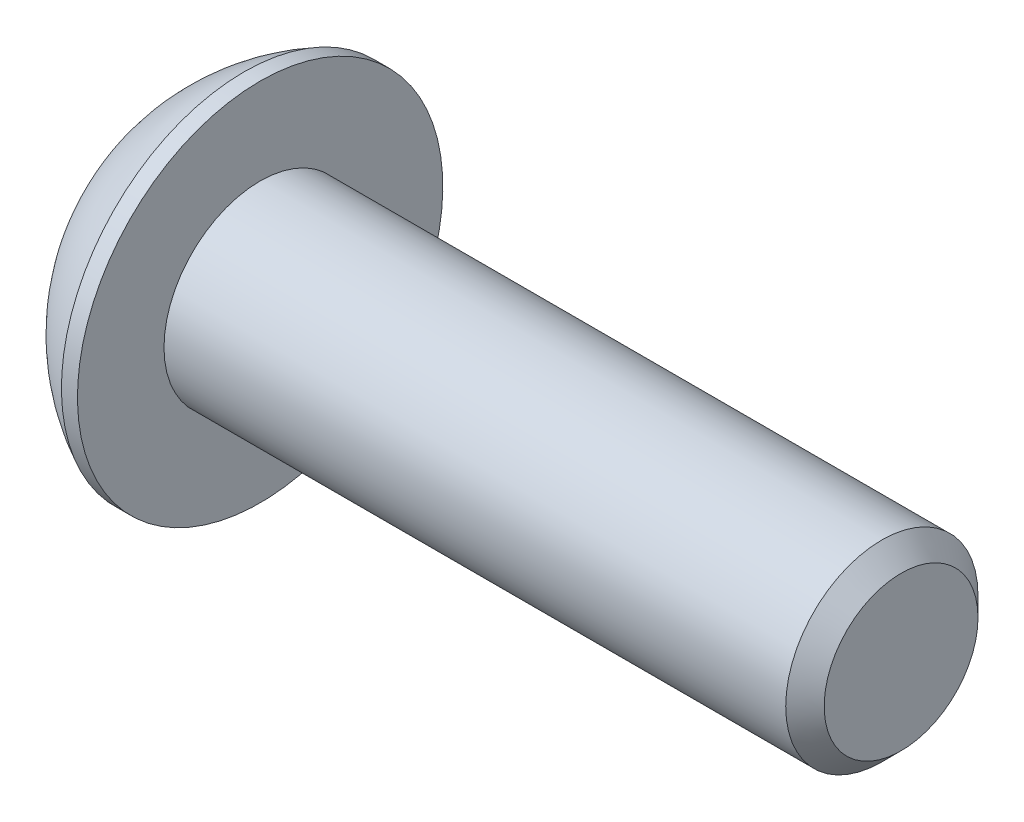
from build123d import *

# Parameters (mm, degrees)
SKETCH2_R           = 1.5
BOSS_EXTRUDE1_DEPTH = 10
CHAMFER1_SIZE       = 0.3
CUT_EXTRUDE1_DEPTH  = 1.2
SKETCH8_R           = 1.204700538
CUT_EXTRUDE2_DEPTH  = 1
CUT_EXTRUDE2_TAPER  = 45


with BuildPart() as part:
    # Sketch2 → Boss-Extrude1 (new body)
    with BuildSketch(Plane(origin=(0, 0, 0), x_dir=(0, 0, -1), z_dir=(1, 0, 0))):
        Circle(SKETCH2_R)
    extrude(amount=-BOSS_EXTRUDE1_DEPTH)

    # Chamfer1
    chamfer1_edges = [part.edges().sort_by_distance(p)[0] for p in [
        (0, 0, 1.5),
    ]]
    chamfer(chamfer1_edges, length=CHAMFER1_SIZE)

    # Sketch6 → Revolve1 (revolve)
    with BuildSketch(Plane.XY):
        with BuildLine():
            Line((-11.65, 0), (-11.65, 1.5))
            ThreePointArc((-11.65, 1.5), (-11.055944823, 2.284868705), (-10.25, 2.85))
            Line((-10.25, 2.85), (-10, 2.85))
            Line((-10, 2.85), (-10, 0))
            Line((-10, 0), (-11.65, 0))
        make_face()
    revolve(axis=Axis((-10, 0, 0), (-1, 0, 0)))

    # Sketch7 → Cut-Extrude1 (cut)
    with BuildSketch(Plane.ZY.offset(11.65)):
        Polygon((0, 1.154700538), (-1, 0.577350269), (-1, -0.577350269), (0, -1.154700538), (1, -0.577350269), (1, 0.577350269), align=None)
    extrude(amount=-CUT_EXTRUDE1_DEPTH, mode=Mode.SUBTRACT)

    # Sketch8 → Cut-Extrude2 (cut)
    with BuildSketch(Plane.ZY.offset(11.65)):
        Circle(SKETCH8_R)
    extrude(amount=-CUT_EXTRUDE2_DEPTH, taper=CUT_EXTRUDE2_TAPER, mode=Mode.SUBTRACT)


solid = part.part
